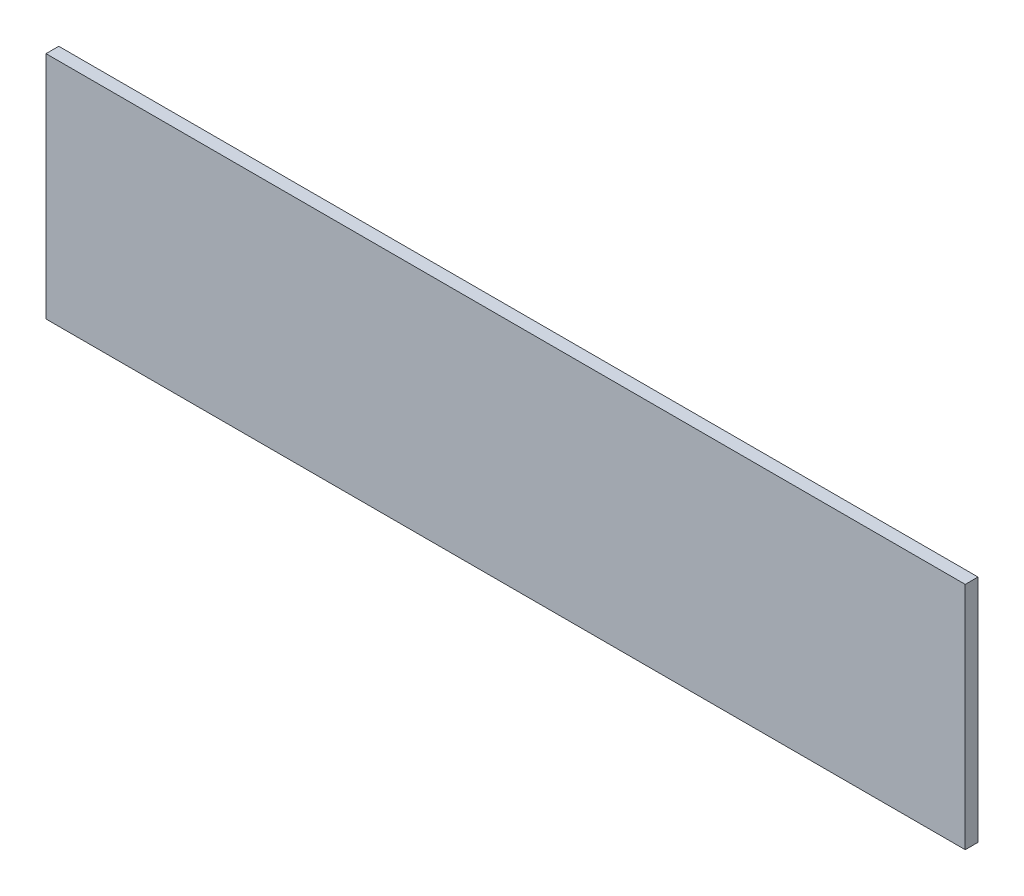
from build123d import *

# Parameters (mm, degrees)
SKETCH_1_W      = 360
SKETCH_1_H      = 90
EXTRUDE_1_DEPTH = 5


with BuildPart() as part:
    # 草图1 → 凸台-拉伸1 (new body)
    with BuildSketch(Plane.XY):
        with Locations((-20, 0)):
            Rectangle(SKETCH_1_W, SKETCH_1_H)
    extrude(amount=EXTRUDE_1_DEPTH)


solid = part.part
